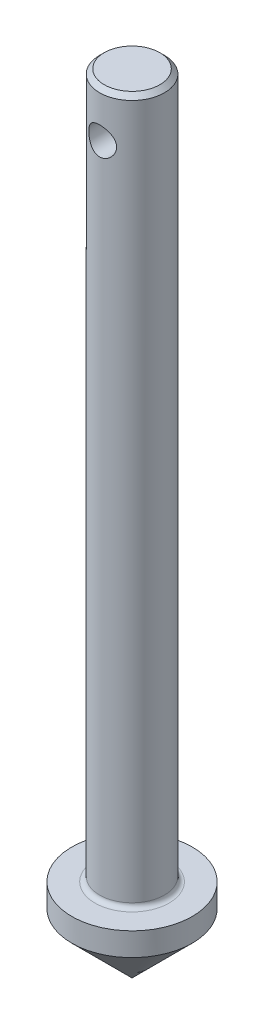
from build123d import *

# Parameters (mm, degrees)
SZKIC2_R                        = 1.5
WYTNIJ_WYCI_GNI_CIE1_DEPTH      = 7.5
WYTNIJ_WYCI_GNI_CIE1_DEPTH_BACK = 7.5
SFAZOWANIE4_SIZE                = 0.5


with BuildPart() as part:
    # Szkic1 → Obrót2 (revolve)
    with BuildSketch(Plane.XY):
        with BuildLine():
            Line((0, 0), (6.5, 6.5))
            Line((6.5, 6.5), (6.5, 9))
            Line((6.5, 9), (4, 9))
            ThreePointArc((4, 9), (3.646446609, 9.146446609), (3.5, 9.5))
            Line((3.5, 9.5), (3.5, 85))
            Line((3.5, 85), (0, 85))
            Line((0, 85), (0, 0))
        make_face()
    revolve(axis=Axis((0, 0, 0), (0, 1, 0)))

    # Szkic2 → Wytnij-wyciągnięcie1 (cut, two sides)
    with BuildSketch(Plane.XY) as wytnij_wyci_gni_cie1_sk:
        with Locations((0, 80)):
            Circle(SZKIC2_R)
    extrude(amount=WYTNIJ_WYCI_GNI_CIE1_DEPTH, mode=Mode.SUBTRACT)
    extrude(wytnij_wyci_gni_cie1_sk.sketch, amount=-WYTNIJ_WYCI_GNI_CIE1_DEPTH_BACK, mode=Mode.SUBTRACT)

    # Sfazowanie4
    sfazowanie4_edges = [part.edges().sort_by_distance(p)[0] for p in [
        (-3.5, 85, 0),
    ]]
    chamfer(sfazowanie4_edges, length=SFAZOWANIE4_SIZE)


solid = part.part
